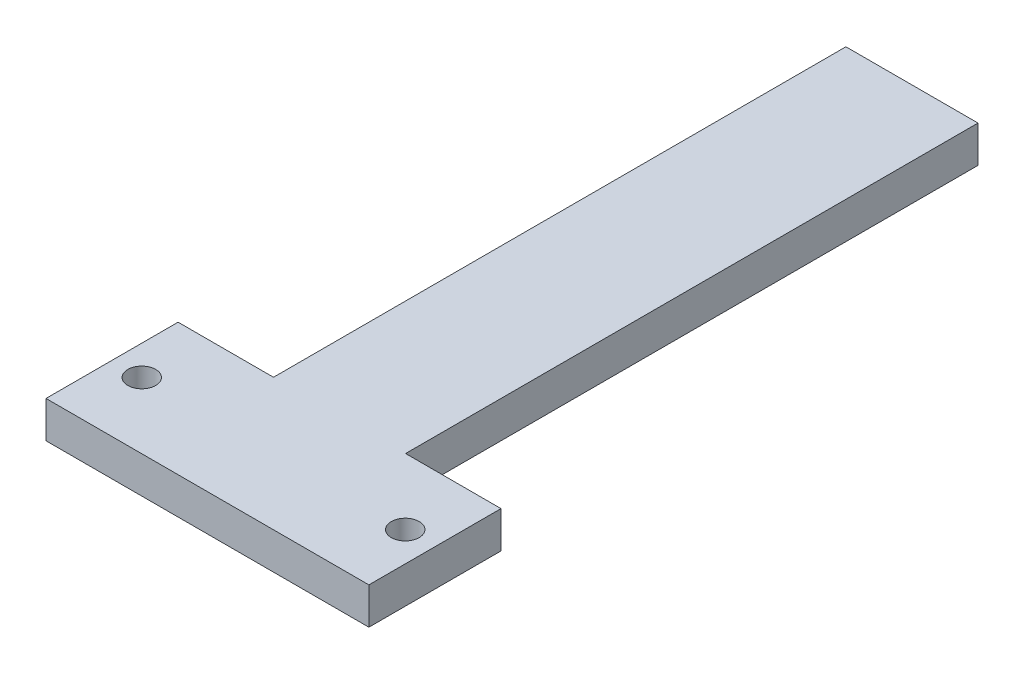
from build123d import *

# Parameters (mm, degrees)
SKETCH1_R           = 2.413
BOSS_EXTRUDE1_DEPTH = 6.35


with BuildPart() as part:
    # Sketch1 → Boss-Extrude1 (new body)
    with BuildSketch(Plane(origin=(0, 0, 0), x_dir=(1, 0, 0), z_dir=(0, 1, 0))):
        Polygon((-27.94, -11.43), (27.94, -11.43), (27.94, 11.43), (11.43, 11.43), (11.43, 110.49), (-11.43, 110.49), (-11.43, 11.43), (-27.94, 11.43), align=None)
        with Locations((-22.7965, 0)):
            Circle(SKETCH1_R, mode=Mode.SUBTRACT)
        with Locations((22.7965, 0)):
            Circle(SKETCH1_R, mode=Mode.SUBTRACT)
    extrude(amount=BOSS_EXTRUDE1_DEPTH)


solid = part.part
